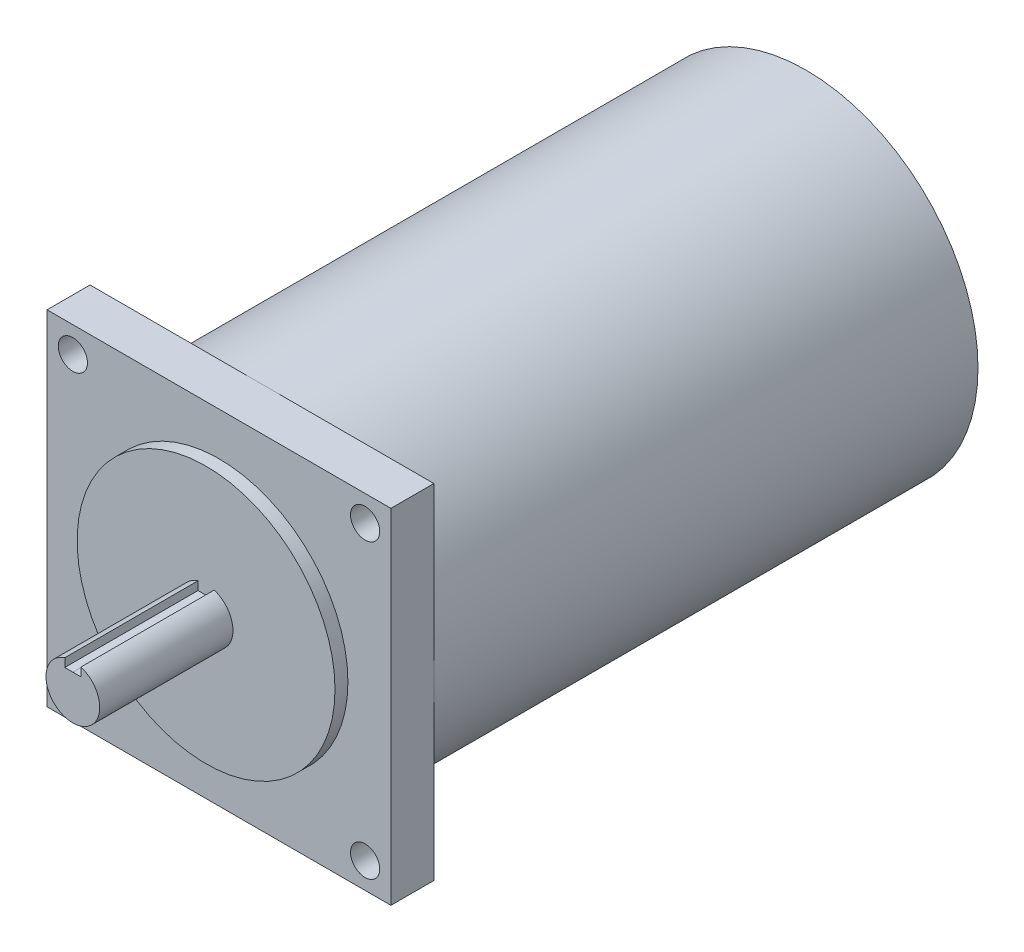
from build123d import *

# Parameters (mm, degrees)
SKETCH1_W               = 101.6
SKETCH1_H               = 101.6
SKETCH1_R               = 4.318
BOSS_EXTRUDE1_DEPTH     = 12.7
SKETCH2_R               = 38.1
BOSS_EXTRUDE2_DEPTH     = 3.81
SKETCH4_R               = 7.9375
BOSS_EXTRUDE4_DEPTH     = 39.37
CUT_EXTRUDE1_DEPTH      = 1
CUT_EXTRUDE1_DEPTH_BACK = 39.37
SKETCH6_R               = 50.8
BOSS_EXTRUDE5_DEPTH     = 160.782
SKETCH7_R               = 38.1
BOSS_EXTRUDE6_DEPTH     = 3.81
SKETCH8_R               = 6.35
BOSS_EXTRUDE7_DEPTH     = 17.78


with BuildPart() as part:
    # Sketch1 → Boss-Extrude1 (new body)
    with BuildSketch(Plane.XY):
        Rectangle(SKETCH1_W, SKETCH1_H)
        with Locations((-43.18, -43.18)):
            Circle(SKETCH1_R, mode=Mode.SUBTRACT)
        with Locations((43.18, -43.18)):
            Circle(SKETCH1_R, mode=Mode.SUBTRACT)
        with Locations((43.18, 43.18)):
            Circle(SKETCH1_R, mode=Mode.SUBTRACT)
        with Locations((-43.18, 43.18)):
            Circle(SKETCH1_R, mode=Mode.SUBTRACT)
    extrude(amount=BOSS_EXTRUDE1_DEPTH)

    # Sketch2 → Boss-Extrude2 (add)
    with BuildSketch(Plane.XY.offset(12.7)):
        Circle(SKETCH2_R)
    extrude(amount=BOSS_EXTRUDE2_DEPTH)

    # Sketch4 → Boss-Extrude4 (add)
    with BuildSketch(Plane.XY.offset(16.51)):
        Circle(SKETCH4_R)
    extrude(amount=BOSS_EXTRUDE4_DEPTH)

    # Sketch5 → Cut-Extrude1 (cut, two sides)
    with BuildSketch(Plane.XY.offset(55.88)) as cut_extrude1_sk:
        with BuildLine():
            Line((-2.387594518, 5.063803231), (5.482e-06, 5.063803231))
            Line((5.482e-06, 5.063803231), (2.387605482, 5.063803231))
            Line((2.387605482, 5.063803231), (2.387605482, 7.569890773))
            ThreePointArc((2.387605482, 7.569890773), (5.748e-06, 7.9375), (-2.387594518, 7.569894231))
            Line((-2.387594518, 7.569894231), (-2.387594518, 5.063803231))
        make_face()
    extrude(amount=CUT_EXTRUDE1_DEPTH, mode=Mode.SUBTRACT)
    extrude(cut_extrude1_sk.sketch, amount=-CUT_EXTRUDE1_DEPTH_BACK, mode=Mode.SUBTRACT)

    # Sketch6 → Boss-Extrude5 (add)
    with BuildSketch(Plane(origin=(0, 0, 0), x_dir=(-1, 0, 0), z_dir=(0, 0, -1))):
        Circle(SKETCH6_R)
    extrude(amount=BOSS_EXTRUDE5_DEPTH)

    # Sketch7 → Boss-Extrude6 (add)
    with BuildSketch(Plane(origin=(0, 0, -160.782), x_dir=(-1, 0, 0), z_dir=(0, 0, -1))):
        Circle(SKETCH7_R)
    extrude(amount=BOSS_EXTRUDE6_DEPTH)

    # Sketch8 → Boss-Extrude7 (add)
    with BuildSketch(Plane(origin=(0, 0, -164.592), x_dir=(-1, 0, 0), z_dir=(0, 0, -1))):
        Circle(SKETCH8_R)
    extrude(amount=BOSS_EXTRUDE7_DEPTH)


solid = part.part
